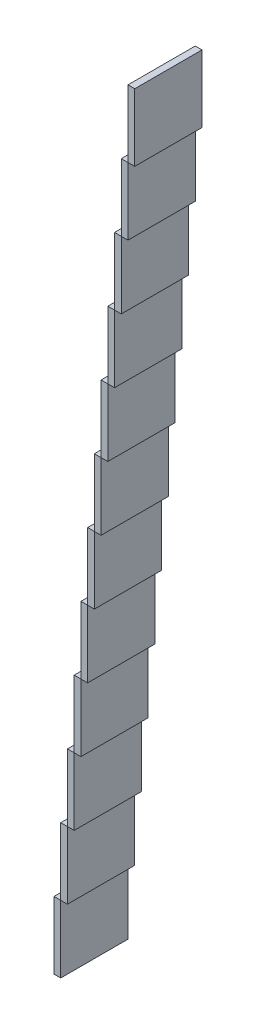
from build123d import *

# Parameters (mm, degrees)
SKETCH2_W              = 1
SKETCH2_H              = 10
BOSS_EXTRUDE1_DEPTH    = 10
BOSS_EXTRUDE1_2_DEPTH  = 10
BOSS_EXTRUDE1_3_DEPTH  = 10
BOSS_EXTRUDE1_4_DEPTH  = 10
BOSS_EXTRUDE1_5_DEPTH  = 10
BOSS_EXTRUDE1_6_DEPTH  = 10
BOSS_EXTRUDE1_7_DEPTH  = 10
BOSS_EXTRUDE1_8_DEPTH  = 10
BOSS_EXTRUDE1_9_DEPTH  = 10
BOSS_EXTRUDE1_10_DEPTH = 10
BOSS_EXTRUDE1_11_DEPTH = 10
BOSS_EXTRUDE1_12_DEPTH = 10


with BuildPart() as part:
    # Sketch2 → Boss-Extrude1 (new body)
    with BuildSketch(Plane.XY):
        with Locations((5.263921221, 5.445606952)):
            Rectangle(SKETCH2_W, SKETCH2_H)
    extrude(amount=BOSS_EXTRUDE1_DEPTH)


with BuildPart() as body_2:
    # Sketch2 → Boss-Extrude1 2 (new body)
    with BuildSketch(Plane.XY):
        with Locations((16.263921221, 115.445606952)):
            Rectangle(SKETCH2_W, SKETCH2_H)
    extrude(amount=BOSS_EXTRUDE1_2_DEPTH)


with BuildPart() as body_3:
    # Sketch2 → Boss-Extrude1 3 (new body)
    with BuildSketch(Plane.XY):
        with Locations((15.263921221, 105.445606952)):
            Rectangle(SKETCH2_W, SKETCH2_H)
    extrude(amount=BOSS_EXTRUDE1_3_DEPTH)


with BuildPart() as body_4:
    # Sketch2 → Boss-Extrude1 4 (new body)
    with BuildSketch(Plane.XY):
        with Locations((14.263921221, 95.445606952)):
            Rectangle(SKETCH2_W, SKETCH2_H)
    extrude(amount=BOSS_EXTRUDE1_4_DEPTH)


with BuildPart() as body_5:
    # Sketch2 → Boss-Extrude1 5 (new body)
    with BuildSketch(Plane.XY):
        with Locations((13.263921221, 85.445606952)):
            Rectangle(SKETCH2_W, SKETCH2_H)
    extrude(amount=BOSS_EXTRUDE1_5_DEPTH)


with BuildPart() as body_6:
    # Sketch2 → Boss-Extrude1 6 (new body)
    with BuildSketch(Plane.XY):
        with Locations((12.263921221, 75.445606952)):
            Rectangle(SKETCH2_W, SKETCH2_H)
    extrude(amount=BOSS_EXTRUDE1_6_DEPTH)


with BuildPart() as body_7:
    # Sketch2 → Boss-Extrude1 7 (new body)
    with BuildSketch(Plane.XY):
        with Locations((11.263921221, 65.445606952)):
            Rectangle(SKETCH2_W, SKETCH2_H)
    extrude(amount=BOSS_EXTRUDE1_7_DEPTH)


with BuildPart() as body_8:
    # Sketch2 → Boss-Extrude1 8 (new body)
    with BuildSketch(Plane.XY):
        with Locations((10.263921221, 55.445606952)):
            Rectangle(SKETCH2_W, SKETCH2_H)
    extrude(amount=BOSS_EXTRUDE1_8_DEPTH)


with BuildPart() as body_9:
    # Sketch2 → Boss-Extrude1 9 (new body)
    with BuildSketch(Plane.XY):
        with Locations((9.263921221, 45.445606952)):
            Rectangle(SKETCH2_W, SKETCH2_H)
    extrude(amount=BOSS_EXTRUDE1_9_DEPTH)


with BuildPart() as body_10:
    # Sketch2 → Boss-Extrude1 10 (new body)
    with BuildSketch(Plane.XY):
        with Locations((8.263921221, 35.445606952)):
            Rectangle(SKETCH2_W, SKETCH2_H)
    extrude(amount=BOSS_EXTRUDE1_10_DEPTH)


with BuildPart() as body_11:
    # Sketch2 → Boss-Extrude1 11 (new body)
    with BuildSketch(Plane.XY):
        with Locations((6.263921221, 15.445606952)):
            Rectangle(SKETCH2_W, SKETCH2_H)
    extrude(amount=BOSS_EXTRUDE1_11_DEPTH)


with BuildPart() as body_12:
    # Sketch2 → Boss-Extrude1 12 (new body)
    with BuildSketch(Plane.XY):
        with Locations((7.263921221, 25.445606952)):
            Rectangle(SKETCH2_W, SKETCH2_H)
    extrude(amount=BOSS_EXTRUDE1_12_DEPTH)


solid = Compound([part.part, body_2.part, body_3.part, body_4.part, body_5.part, body_6.part, body_7.part, body_8.part, body_9.part, body_10.part, body_11.part, body_12.part])
